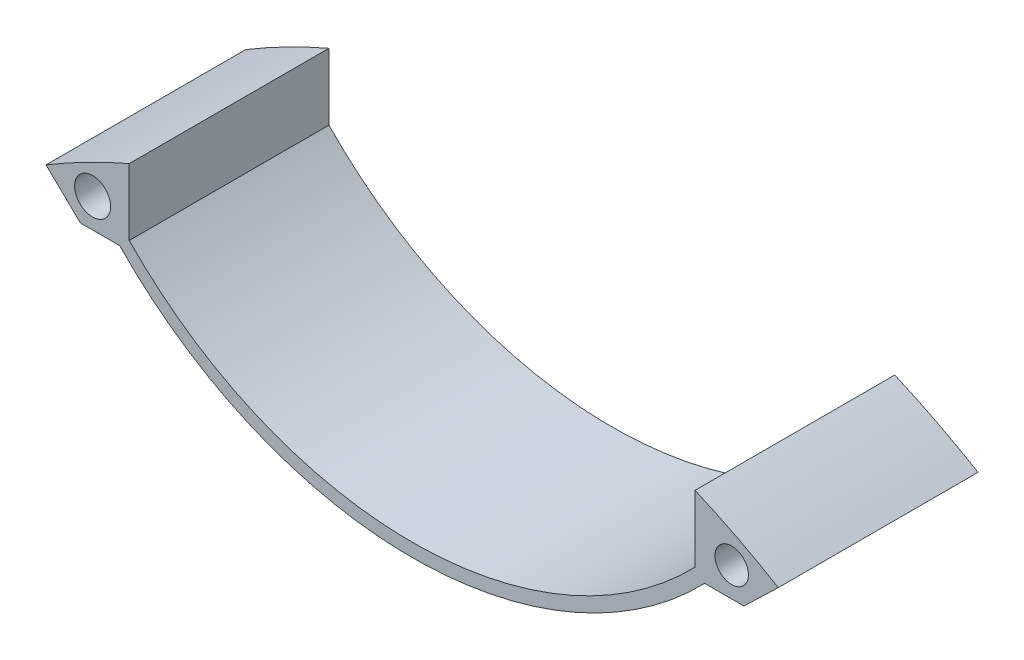
from build123d import *

# Parameters (mm, degrees)
SKETCH1_R           = 2.702962803
SKETCH1_R_2         = 2.510598202
BOSS_EXTRUDE1_DEPTH = 30


with BuildPart() as part:
    # Sketch1 → Boss-Extrude1 (new body)
    with BuildSketch(Plane.XY):
        with BuildLine():
            Line((-42.5, -8.80249494), (-42.5, -18.80249494))
            ThreePointArc((-42.5, -18.80249494), (0, -36.80249494), (42.5, -18.80249494))
            Line((42.5, -18.80249494), (42.5, -8.80249494))
            ThreePointArc((42.5, -8.80249494), (48.855409625, -11.804679997), (55, -15.217648755))
            Line((55, -15.217648755), (49.831703302, -20.194115642))
            Line((49.831703302, -20.194115642), (43.936451121, -20.194115642))
            ThreePointArc((43.936451121, -20.194115642), (0, -38.80249494), (-43.936451121, -20.194115642))
            Line((-43.936451121, -20.194115642), (-49.831703302, -20.194115642))
            Line((-49.831703302, -20.194115642), (-55, -15.217648755))
            ThreePointArc((-55, -15.217648755), (-48.855409625, -11.804679997), (-42.5, -8.80249494))
        make_face()
        with Locations((-48, -15.80249494)):
            Circle(SKETCH1_R, mode=Mode.SUBTRACT)
        with Locations((48, -15.80249494)):
            Circle(SKETCH1_R_2, mode=Mode.SUBTRACT)
    extrude(amount=BOSS_EXTRUDE1_DEPTH)


solid = part.part
